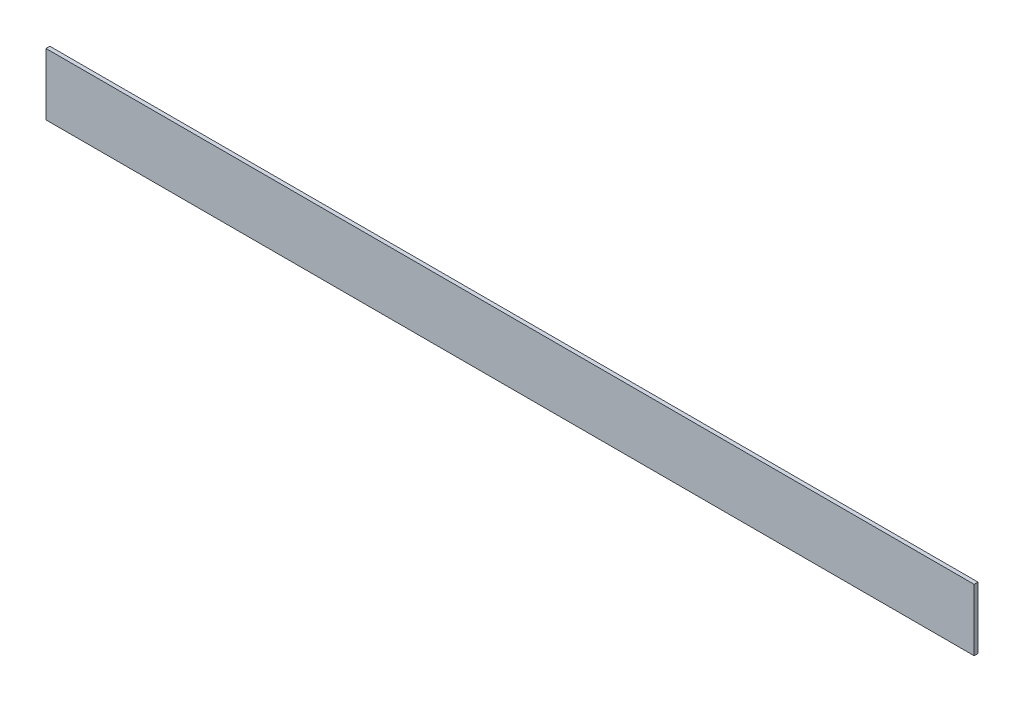
from build123d import *

# Parameters (mm, degrees)
SKETCH1_W           = 762
SKETCH1_H           = 50.8
BOSS_EXTRUDE1_DEPTH = 3.175


with BuildPart() as part:
    # Sketch1 → Boss-Extrude1 (new body)
    with BuildSketch(Plane.XY):
        with Locations((-381, -25.4)):
            Rectangle(SKETCH1_W, SKETCH1_H)
    extrude(amount=BOSS_EXTRUDE1_DEPTH)


solid = part.part
